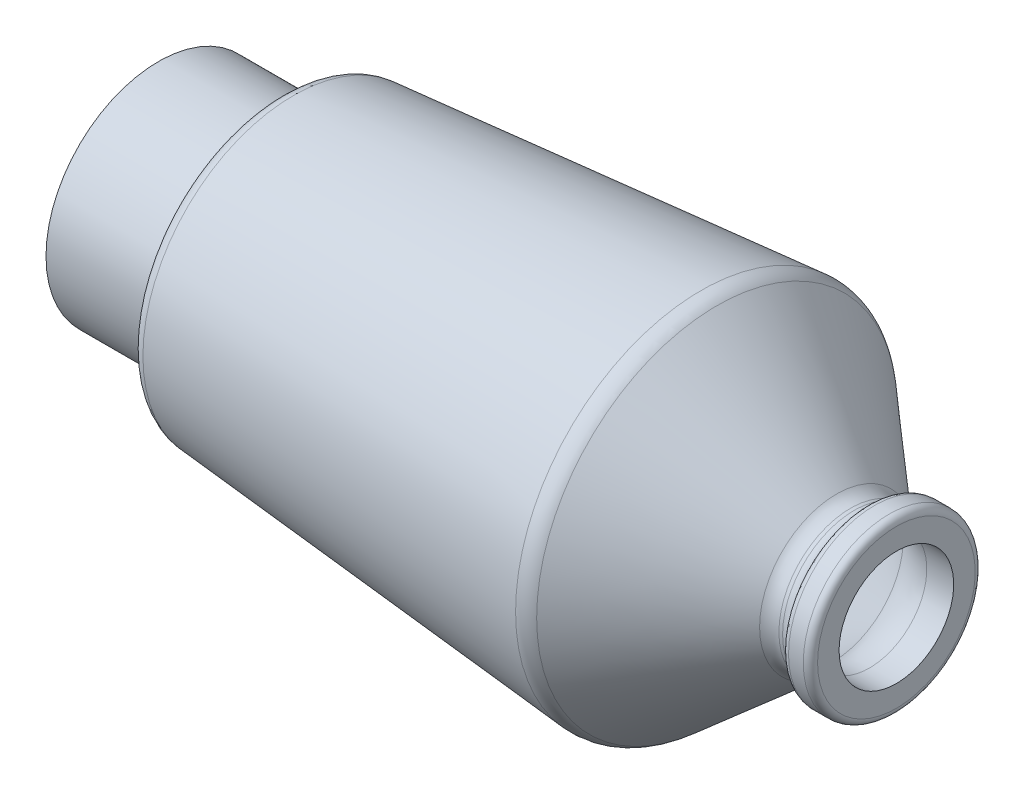
from build123d import *


with BuildPart() as part:
    # Sketch1 → Revolve1 (revolve)
    with BuildSketch(Plane.XY, mode=Mode.PRIVATE) as revolve1_sk:
        with BuildLine():
            Line((0, 7.85), (7.5, 7.85))
            ThreePointArc((7.5, 7.85), (8.207106781, 8.142893219), (8.5, 8.85))
            Line((8.5, 8.85), (8.5, 9.503673623))
            ThreePointArc((8.5, 9.503673623), (8.763237719, 10.179825486), (9.414362683, 10.5))
            Line((9.414362683, 10.5), (37.868765738, 12.945743473))
            ThreePointArc((37.868765738, 12.945743473), (38.460380715, 12.87795771), (38.979001176, 12.585321404))
            Line((38.979001176, 12.585321404), (47.318220538, 5.365932503))
            ThreePointArc((47.318220538, 5.365932503), (47.776120837, 5.094457179), (48.3, 5))
            Line((48.3, 5), (48.557190958, 5))
            ThreePointArc((48.557190958, 5), (49.134541228, 5.183503419), (49.5, 5.666666667))
            ThreePointArc((49.5, 5.666666667), (49.682729386, 5.90824829), (49.971404521, 6))
            Line((49.971404521, 6), (51, 6))
            ThreePointArc((51, 6), (51.353553391, 5.853553391), (51.5, 5.5))
            Line((51.5, 5.5), (51.5, 4))
            Line((51.5, 4), (49.62300461, 4))
            ThreePointArc((49.62300461, 4), (48.225993509, 4.25188581), (47.004926044, 4.975820008))
            Line((47.004926044, 4.975820008), (38.651741355, 12.207298906))
            ThreePointArc((38.651741355, 12.207298906), (38.305994381, 12.402389776), (37.911584397, 12.447580285))
            Line((37.911584397, 12.447580285), (9.457181342, 10.001836811))
            ThreePointArc((9.457181342, 10.001836811), (9.13161886, 9.841749554), (9, 9.503673623))
            Line((9, 9.503673623), (9, 8.85))
            ThreePointArc((9, 8.85), (8.560660172, 7.789339828), (7.5, 7.35))
            Line((7.5, 7.35), (0, 7.35))
            Line((0, 7.35), (0, 7.85))
        make_face()
    revolve(revolve1_sk.sketch.rotate(Axis((0, 0, 0), (1, 0, 0)), 90), axis=Axis((0, 0, 0), (1, 0, 0)))  # turned: the seam where the file's is


solid = part.part
